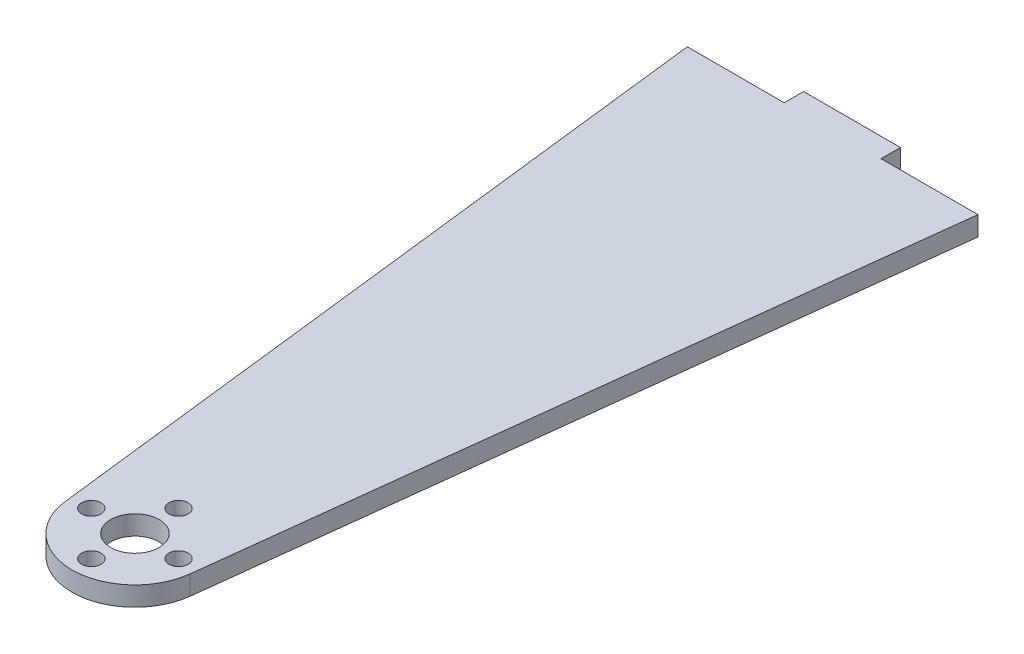
from build123d import *

# Parameters (mm, degrees)
SKETCH2_R           = 7.9375
SKETCH2_R_2         = 3.175
BOSS_EXTRUDE1_DEPTH = 6.35


with BuildPart() as part:
    # Sketch2 → Boss-Extrude1 (new body)
    with BuildSketch(Plane(origin=(0, 69.85, 0), x_dir=(1, 0, 0), z_dir=(0, 1, 0))):
        with BuildLine():
            Line((-15.875, 6.35), (15.875, 6.35))
            Line((15.875, 6.35), (15.875, 0))
            Line((15.875, 0), (47.625, 0))
            Line((47.625, 0), (20.496649102, -231.007027591))
            ThreePointArc((20.496649102, -231.007027591), (0, -249.2375), (-20.496649102, -231.007027591))
            Line((-20.496649102, -231.007027591), (-47.625, 0))
            Line((-47.625, 0), (-15.875, 0))
            Line((-15.875, 0), (-15.875, 6.35))
        make_face()
        with Locations((0, -228.6)):
            Circle(SKETCH2_R, mode=Mode.SUBTRACT)
        with Locations((0, -214.3125)):
            Circle(SKETCH2_R_2, mode=Mode.SUBTRACT)
        with Locations((14.2875, -228.6)):
            Circle(SKETCH2_R_2, mode=Mode.SUBTRACT)
        with Locations((0, -242.8875)):
            Circle(SKETCH2_R_2, mode=Mode.SUBTRACT)
        with Locations((-14.2875, -228.6)):
            Circle(SKETCH2_R_2, mode=Mode.SUBTRACT)
    extrude(amount=BOSS_EXTRUDE1_DEPTH)


solid = part.part
